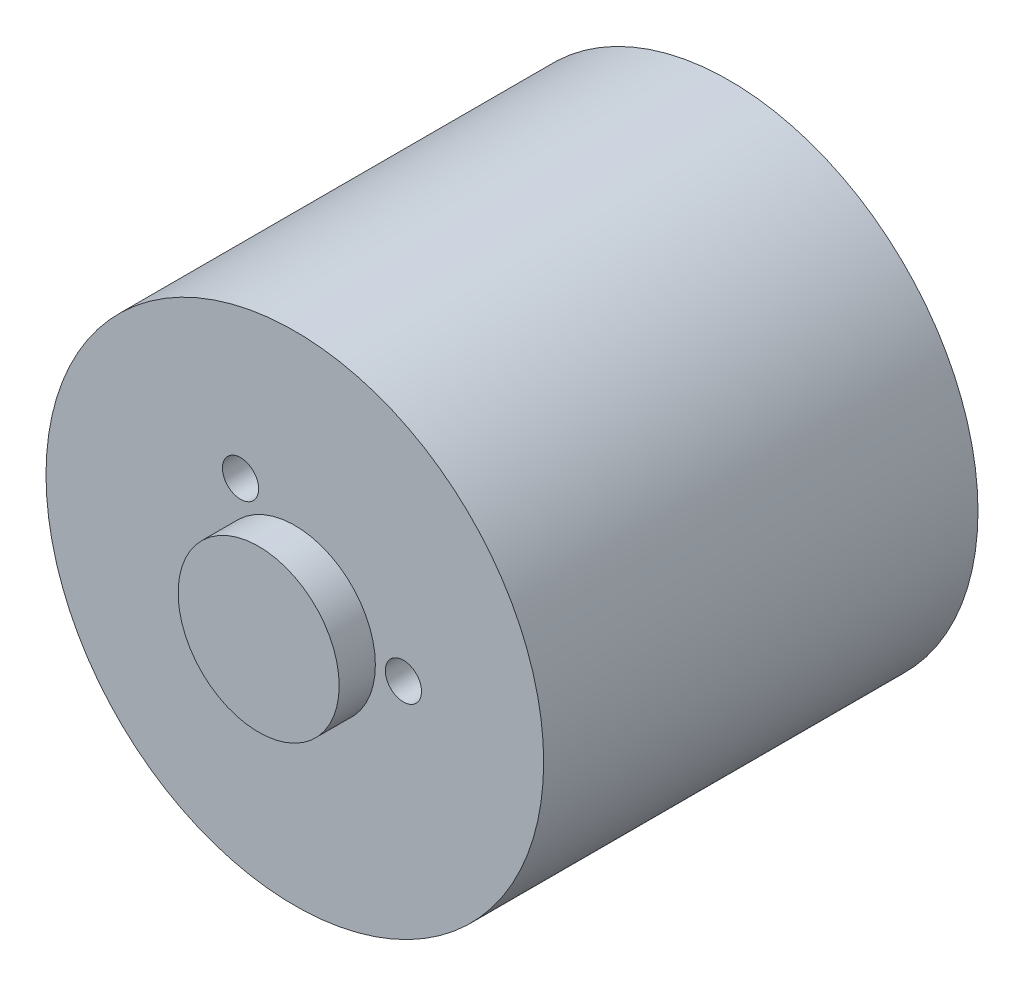
from build123d import *

# Parameters (mm, degrees)
SKETCH_1_R          = 13.75
EXTRUDE_1_DEPTH     = 24
SKETCH_2_R          = 4.45
EXTRUDE_2_DEPTH     = 2
SKETCH_3_R          = 1
CUT_EXTRUDE_1_DEPTH = 6


with BuildPart() as part:
    # 草图1 → 凸台-拉伸1 (new body)
    with BuildSketch(Plane.XY):
        Circle(SKETCH_1_R)
    extrude(amount=EXTRUDE_1_DEPTH)

    # 草图2 → 凸台-拉伸2 (add)
    with BuildSketch(Plane.XY.offset(24)):
        Circle(SKETCH_2_R)
    extrude(amount=EXTRUDE_2_DEPTH)

    # 草图3 → 切除-拉伸1 (cut)
    with BuildSketch(Plane.XY.offset(26)):
        with Locations((6, 0)):
            Circle(SKETCH_3_R)
        with Locations((-3, -5.196152423)):
            Circle(SKETCH_3_R)
        with Locations((-3, 5.196152423)):
            Circle(SKETCH_3_R)
    extrude(amount=-CUT_EXTRUDE_1_DEPTH, mode=Mode.SUBTRACT)


solid = part.part
